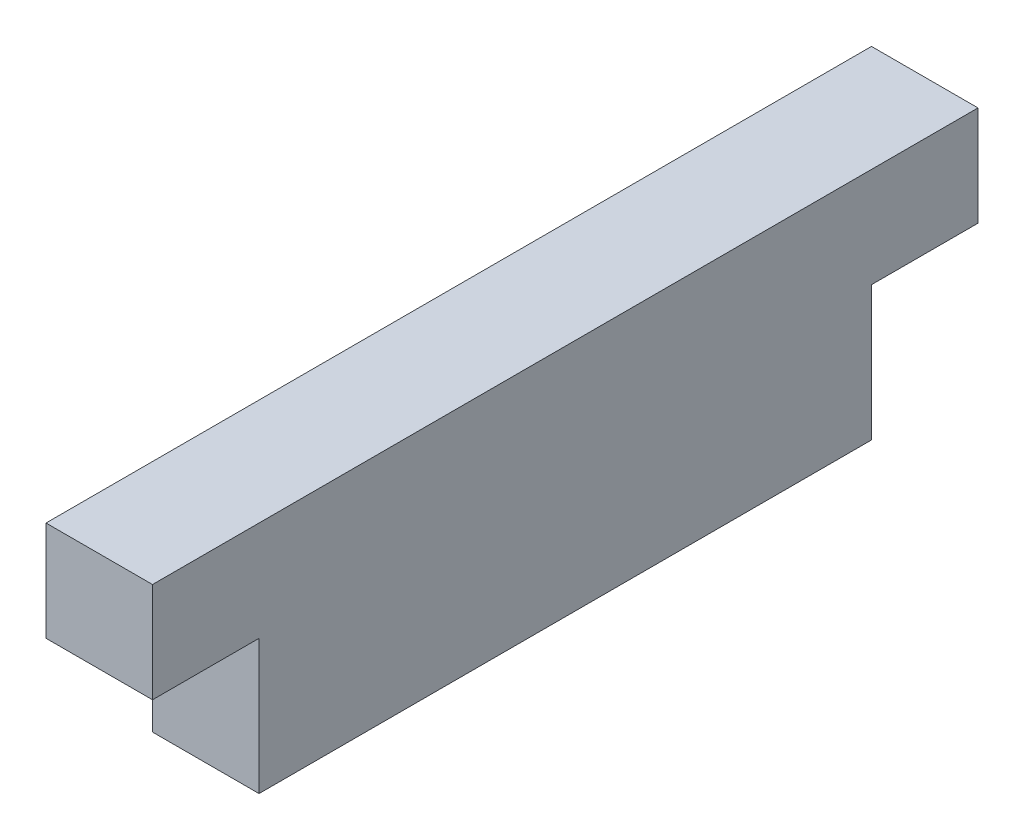
from build123d import *

# Parameters (mm, degrees)
SKETCH1_W           = 29.21
SKETCH1_H           = 11.176
SKETCH1_W_2         = 5.08
SKETCH1_H_2         = 4.7625
BOSS_EXTRUDE1_DEPTH = 5.08


with BuildPart() as part:
    # Sketch1 → Boss-Extrude1 (new body)
    with BuildSketch(Plane(origin=(0, 0, 0), x_dir=(0, 0, -1), z_dir=(1, 0, 0))):
        Rectangle(SKETCH1_W, SKETCH1_H)
        Polygon((-14.605, 0.8255), (-14.605, -5.588), (14.605, -5.588), (14.605, 0.8255), (14.605, 5.588), (-14.605, 5.588), align=None)
        with Locations((-17.145, 3.20675)):
            Rectangle(SKETCH1_W_2, SKETCH1_H_2)
        with Locations((17.145, 3.20675)):
            Rectangle(SKETCH1_W_2, SKETCH1_H_2)
    extrude(amount=BOSS_EXTRUDE1_DEPTH)


solid = part.part
